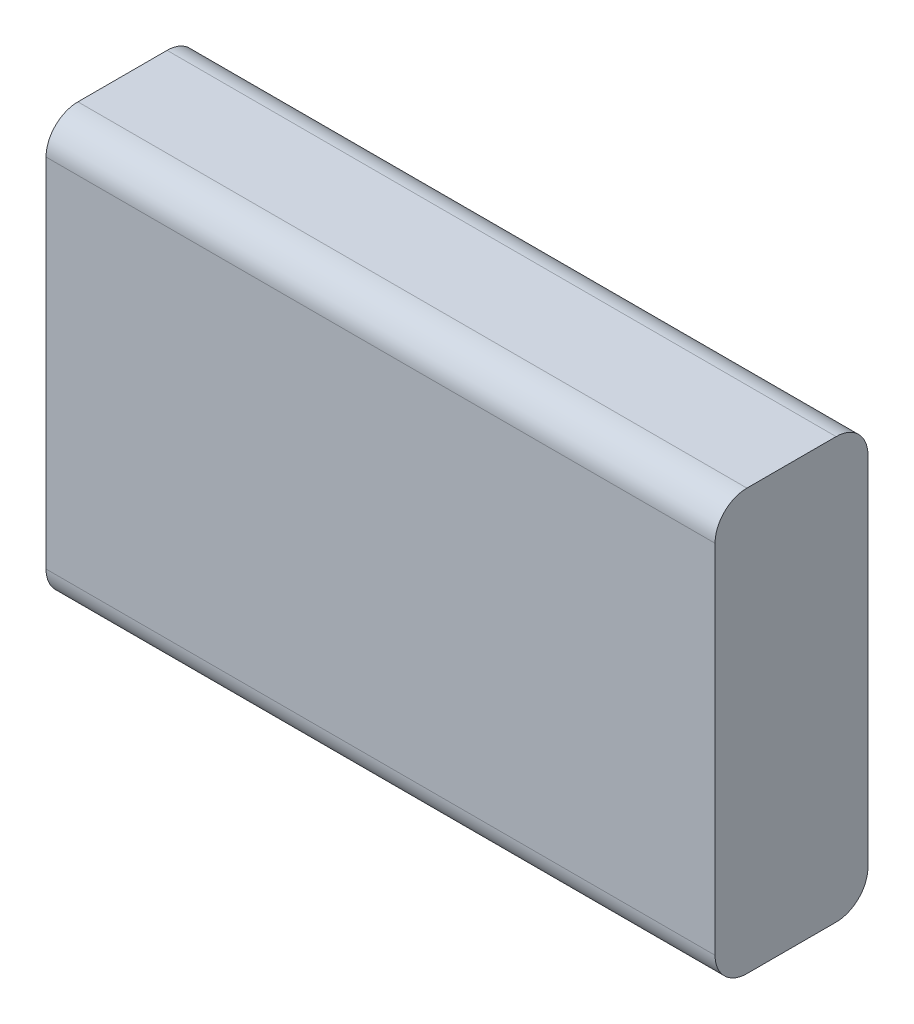
from build123d import *

# Parameters (mm, degrees)
SKETCH1_W           = 105
SKETCH1_H           = 66
BOSS_EXTRUDE1_DEPTH = 24
FILLET1_R           = 5


with BuildPart() as part:
    # Sketch1 → Boss-Extrude1 (new body)
    with BuildSketch(Plane.XY):
        with Locations((47.413211427, 31.324183653)):
            Rectangle(SKETCH1_W, SKETCH1_H)
    extrude(amount=BOSS_EXTRUDE1_DEPTH)

    # Fillet1
    fillet1_edges = [part.edges().sort_by_distance(p)[0] for p in [
        (47.413211427, 64.324183653, 24),
        (47.413211427, 64.324183653, 0),
        (47.413211427, -1.675816347, 0),
        (47.413211427, -1.675816347, 24),
    ]]
    fillet(fillet1_edges, radius=FILLET1_R)


solid = part.part
